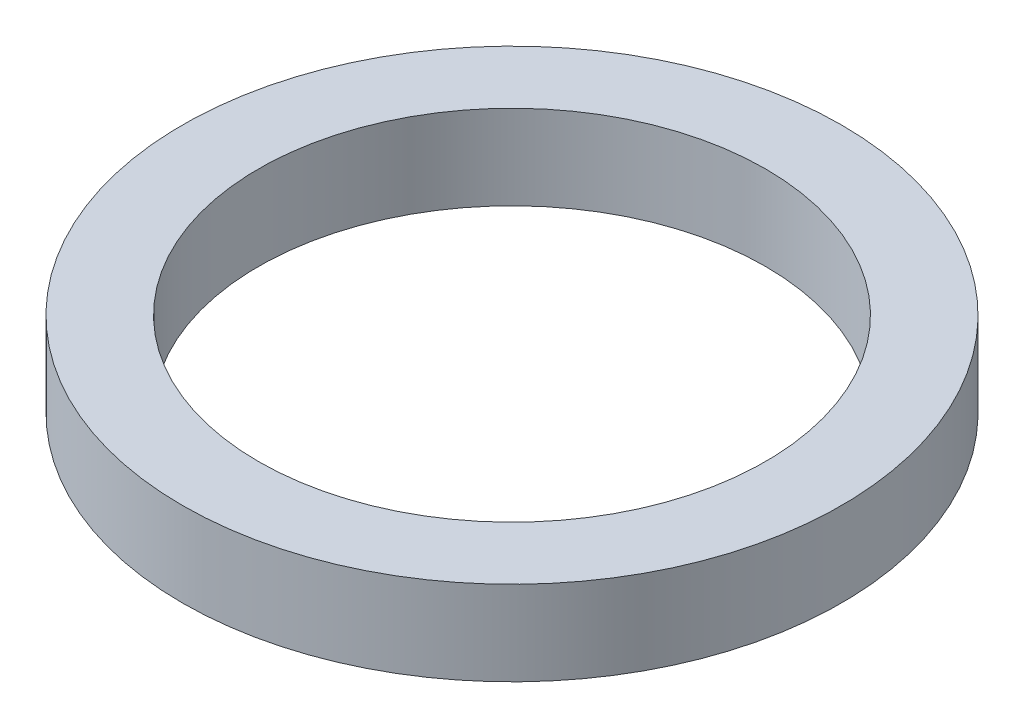
from build123d import *

# Parameters (mm, degrees)
SKETCH1_R           = 39
SKETCH1_R_2         = 30
BOSS_EXTRUDE1_DEPTH = 10


with BuildPart() as part:
    # Sketch1 → Boss-Extrude1 (new body)
    with BuildSketch(Plane(origin=(0, 0, 0), x_dir=(1, 0, 0), z_dir=(0, 1, 0))):
        Circle(SKETCH1_R)
        Circle(SKETCH1_R_2, mode=Mode.SUBTRACT)
    extrude(amount=BOSS_EXTRUDE1_DEPTH)


solid = part.part
